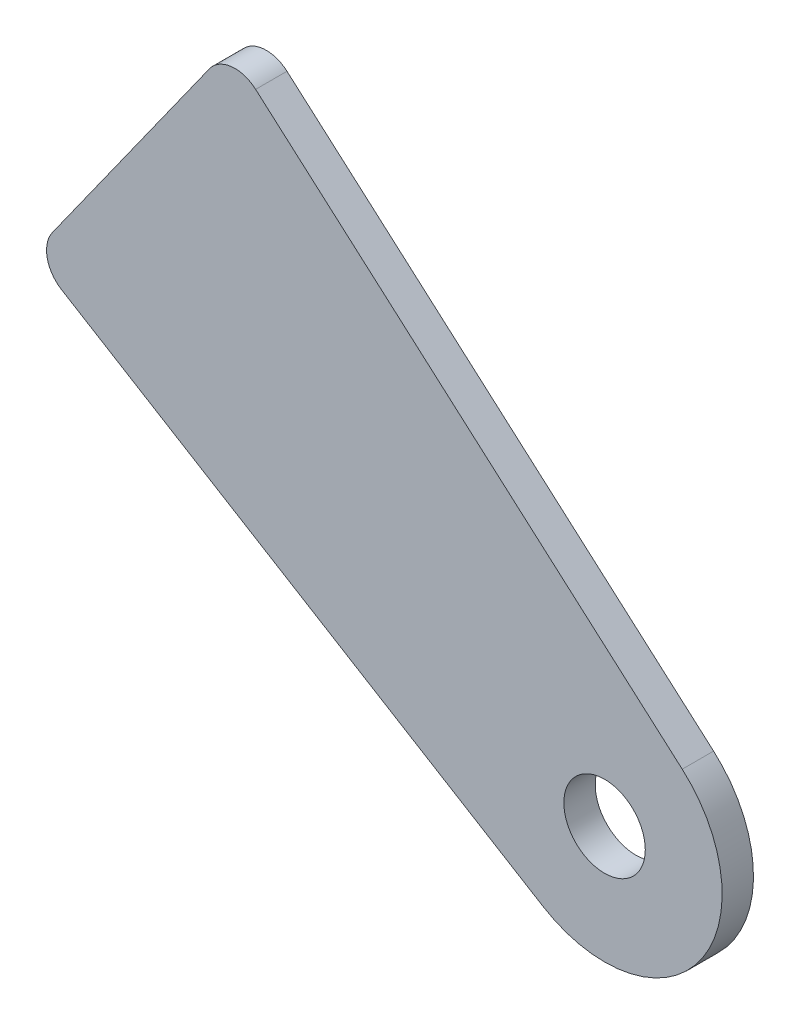
from build123d import *

# Parameters (mm, degrees)
SKETCH1_R           = 3.3
BOSS_EXTRUDE3_DEPTH = 2.54
FILLET1_R           = 2.54
FILLET2_R           = 2.54


with BuildPart() as part:
    # Sketch1 → Boss-Extrude3 (new body)
    with BuildSketch(Plane.XY):
        with BuildLine():
            Line((32.190295112, -35.281999932), (-9.173256028, -10.079873667))
            Line((-9.173256028, -10.079873667), (6.764957958, 12.279616129))
            Line((6.764957958, 12.279616129), (43.439198939, -19.997724209))
            ThreePointArc((43.439198939, -19.997724209), (44.817595988, -32.793810869), (32.190295112, -35.281999932))
        make_face()
        with Locations((37.146277839, -27.14788288)):
            Circle(SKETCH1_R, mode=Mode.SUBTRACT)
    extrude(amount=BOSS_EXTRUDE3_DEPTH)

    # Fillet1
    fillet1_edges = [part.edges().sort_by_distance(p)[0] for p in [
        (-9.173256028, -10.079873667, 1.27),
    ]]
    fillet(fillet1_edges, radius=FILLET1_R)

    # Fillet2
    fillet2_edges = [part.edges().sort_by_distance(p)[0] for p in [
        (6.764957958, 12.279616129, 1.27),
    ]]
    fillet(fillet2_edges, radius=FILLET2_R)


solid = part.part
